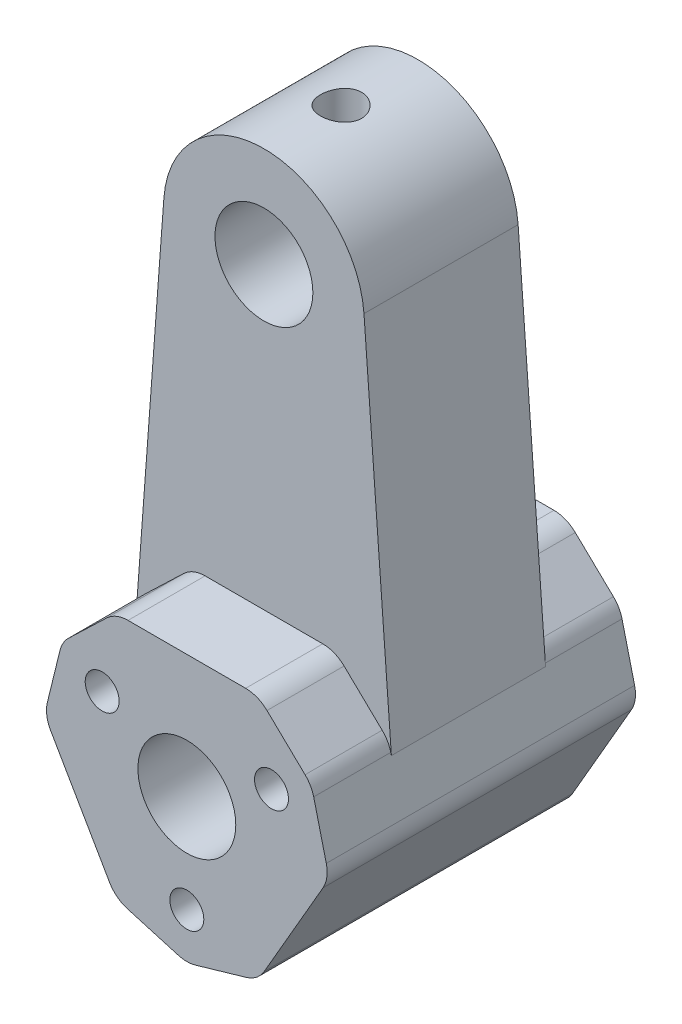
from build123d import *

# Parameters (mm, degrees)
SKETCH1_R           = 4.7625
SKETCH1_R_2         = 1.65
BOSS_EXTRUDE1_DEPTH = 15
SKETCH2_R           = 4.7625
BOSS_EXTRUDE2_DEPTH = 7.5
CUT_EXTRUDE1_REACH  = 66.755
SKETCH3_R           = 2


with BuildPart() as part:
    # Sketch1 → Boss-Extrude1 (new body, symmetric)
    with BuildSketch(Plane.XY):
        with BuildLine():
            Line((-13.253372163, -1.044486042), (-7.531237528, -10.955513958))
            ThreePointArc((-7.531237528, -10.955513958), (-6.784217233, -11.816359568), (-5.770008435, -12.336431676))
            Line((-5.770008435, -12.336431676), (-0.836847118, -13.76941319))
            ThreePointArc((-0.836847118, -13.76941319), (0, -13.888495471), (0.836847118, -13.76941319))
            Line((0.836847118, -13.76941319), (5.770008435, -12.336431676))
            ThreePointArc((5.770008435, -12.336431676), (6.784217233, -11.816359568), (7.531237528, -10.955513958))
            Line((7.531237528, -10.955513958), (13.253372163, -1.044486042))
            ThreePointArc((13.253372163, -1.044486042), (13.625376182, 0.032875315), (13.568667441, 1.171241953))
            Line((13.568667441, 1.171241953), (12.343085176, 6.159975731))
            ThreePointArc((12.343085176, 6.159975731), (12.027789898, 6.944247736), (11.506238058, 7.609437458))
            Line((11.506238058, 7.609437458), (7.798659006, 11.165189723))
            ThreePointArc((7.798659006, 11.165189723), (6.841158949, 11.783484253), (5.722134635, 12))
            Line((5.722134635, 12), (-5.722134635, 12))
            ThreePointArc((-5.722134635, 12), (-6.841158949, 11.783484253), (-7.798659006, 11.165189723))
            Line((-7.798659006, 11.165189723), (-11.506238058, 7.609437458))
            ThreePointArc((-11.506238058, 7.609437458), (-12.027789898, 6.944247736), (-12.343085176, 6.159975731))
            Line((-12.343085176, 6.159975731), (-13.568667441, 1.171241953))
            ThreePointArc((-13.568667441, 1.171241953), (-13.625376182, 0.032875315), (-13.253372163, -1.044486042))
        make_face()
        Circle(SKETCH1_R, mode=Mode.SUBTRACT)
        with Locations((-8.238066653, 4.75625)):
            Circle(SKETCH1_R_2, mode=Mode.SUBTRACT)
        with Locations((8.238066653, 4.75625)):
            Circle(SKETCH1_R_2, mode=Mode.SUBTRACT)
        with Locations((0, -9.5125)):
            Circle(SKETCH1_R_2, mode=Mode.SUBTRACT)
    extrude(amount=BOSS_EXTRUDE1_DEPTH, both=True)

    # Sketch2 → Boss-Extrude2 (add, symmetric)
    with BuildSketch(Plane.XY):
        with BuildLine():
            Line((-12.421472807, 5.666457921), (-9.735682804, 41.826981922))
            ThreePointArc((-9.735682804, 41.826981922), (0, 50.866372944), (9.735682804, 41.826981922))
            Line((9.735682804, 41.826981922), (12.421472807, 5.666457921))
            Line((12.421472807, 5.666457921), (0, 12))
            Line((0, 12), (-12.421472807, 5.666457921))
        make_face()
        with Locations((0, 41.103872944)):
            Circle(SKETCH2_R, mode=Mode.SUBTRACT)
    extrude(amount=BOSS_EXTRUDE2_DEPTH, both=True)

    # Sketch3 → Cut-Extrude1 (cut, up to next)
    with BuildSketch(Plane(origin=(0, 50.866372944, 0), x_dir=(1, 0, 0), z_dir=(0, 1, 0)), mode=Mode.PRIVATE) as cut_extrude1_sk1:
        Circle(SKETCH3_R)
    cut_extrude1_tool1 = extrude(cut_extrude1_sk1.sketch, amount=-CUT_EXTRUDE1_REACH, mode=Mode.PRIVATE) & part.part
    add(cut_extrude1_tool1.solids().sort_by_distance((0, 50.866373, 0))[0], mode=Mode.SUBTRACT)


solid = part.part
